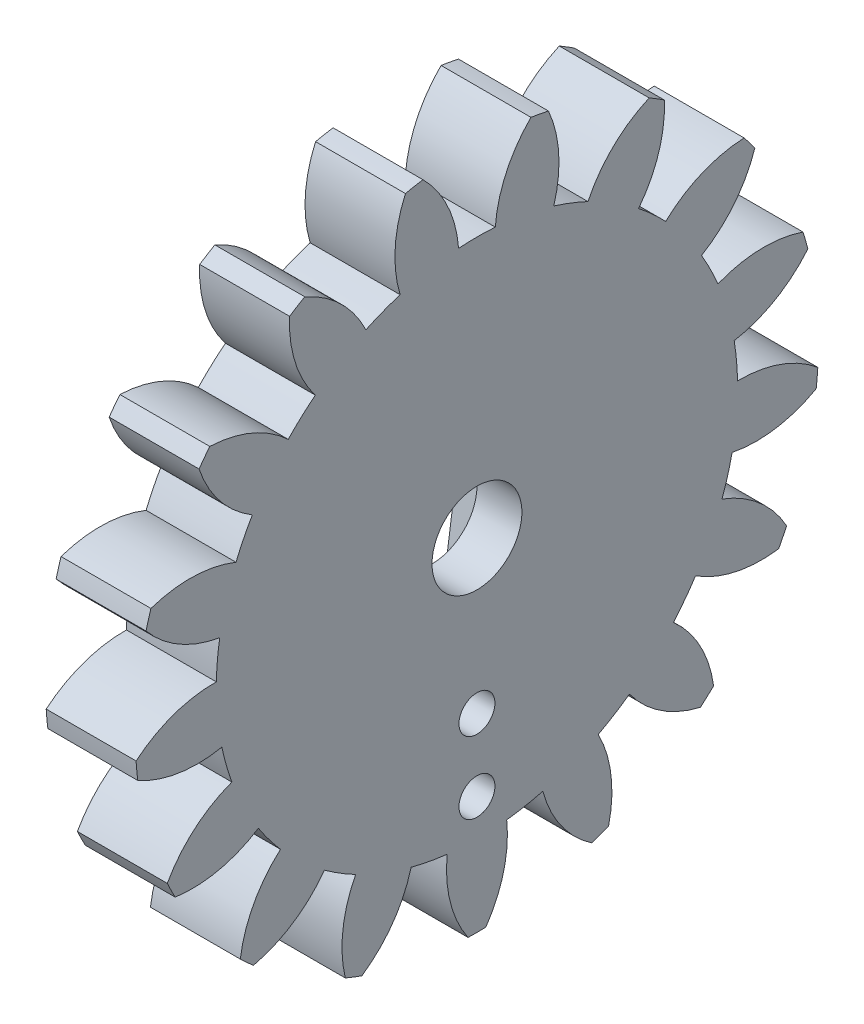
from build123d import *

# Parameters (mm, degrees)
BASPROSKE_W             = 10
BASPROSKE_H             = 19
TOOTHCUT_DEPTH          = 29.670542374
TEETHCUTS_COUNT         = 17
TEETHCUTS_ANGLE         = 338.823529412
BORSKE_R                = 2.5
BORE_DEPTH              = 50.0008636
CUT_EXTRUDE1_DEPTH      = 20
CUT_EXTRUDE1_DEPTH_BACK = 20
SKETCH1_W               = 10
SKETCH1_H               = 40
CUT_EXTRUDE3_DEPTH      = 2.5
SKETCH3_R               = 1
CUT_EXTRUDE4_DEPTH      = 27.95667967


with BuildPart() as part:
    # BasProSke → Base-Revolve (revolve)
    with BuildSketch(Plane(origin=(0, 0, 0), x_dir=(1, 0, 0), z_dir=(0, 1, 0))):
        with Locations((5, 9.5)):
            Rectangle(BASPROSKE_W, BASPROSKE_H)
    revolve(axis=Axis((-10, 0, 0), (1, 0, 0)))

    # TooCutSke → ToothCut (cut, through all)
    with BuildSketch(Plane(origin=(0, 0, 0), x_dir=(0, 0, -1), z_dir=(1, 0, 0))):
        with BuildLine():
            ThreePointArc((1.020352389, 14.463052306), (0, 14.499), (-1.020352389, 14.463052306))
            ThreePointArc((-1.020352389, 14.463052306), (-1.632621885, 16.804485203), (-3.026143023, 18.783192049))
            ThreePointArc((-3.026143023, 18.783192049), (0, 19.0254), (3.026143023, 18.783192049))
            ThreePointArc((3.026143023, 18.783192049), (1.632621885, 16.804485203), (1.020352389, 14.463052306))
        make_face()
    toothcut = extrude(amount=TOOTHCUT_DEPTH, mode=Mode.SUBTRACT)

    # TeethCuts: ToothCut ×17 about axis
    teethcuts_axis = Axis((-10, 0, 0), (1, 0, 0))
    for i in range(1, TEETHCUTS_COUNT):
        add(toothcut.rotate(teethcuts_axis, i * TEETHCUTS_ANGLE / (TEETHCUTS_COUNT - 1)), mode=Mode.SUBTRACT)

    # BorSke → Bore (cut, symmetric)
    with BuildSketch(Plane(origin=(0, 0, 0), x_dir=(0, 0, -1), z_dir=(1, 0, 0))):
        Circle(BORSKE_R)
    extrude(amount=BORE_DEPTH, both=True, mode=Mode.SUBTRACT)

    # Sketch1 → Cut-Extrude1 (cut, two sides: drawn at the far end of the back side and taken through both)
    with BuildSketch(Plane.XY.offset(-CUT_EXTRUDE1_DEPTH_BACK)):
        Rectangle(SKETCH1_W, SKETCH1_H)
    extrude(amount=CUT_EXTRUDE1_DEPTH + CUT_EXTRUDE1_DEPTH_BACK, mode=Mode.SUBTRACT)

    # Sketch2 → Cut-Extrude3 (cut)
    with BuildSketch(Plane.ZY.offset(-5)):
        with BuildLine():
            Line((2, -14.5), (4, 0))
            ThreePointArc((4, 0), (-0.279231906, 3.99024179), (-3.961014771, -0.557101411))
            Line((-3.961014771, -0.557101411), (-2, -14.5))
            ThreePointArc((-2, -14.5), (0, -16.5), (2, -14.5))
        make_face()
    extrude(amount=-CUT_EXTRUDE3_DEPTH, mode=Mode.SUBTRACT)

    # Sketch3 → Cut-Extrude4 (cut, through all)
    with BuildSketch(Plane.ZY.offset(-7.5)):
        with Locations((0, -12.45)):
            Circle(SKETCH3_R)
        with Locations((0, -8.45)):
            Circle(SKETCH3_R)
    extrude(amount=-CUT_EXTRUDE4_DEPTH, mode=Mode.SUBTRACT)


solid = part.part
